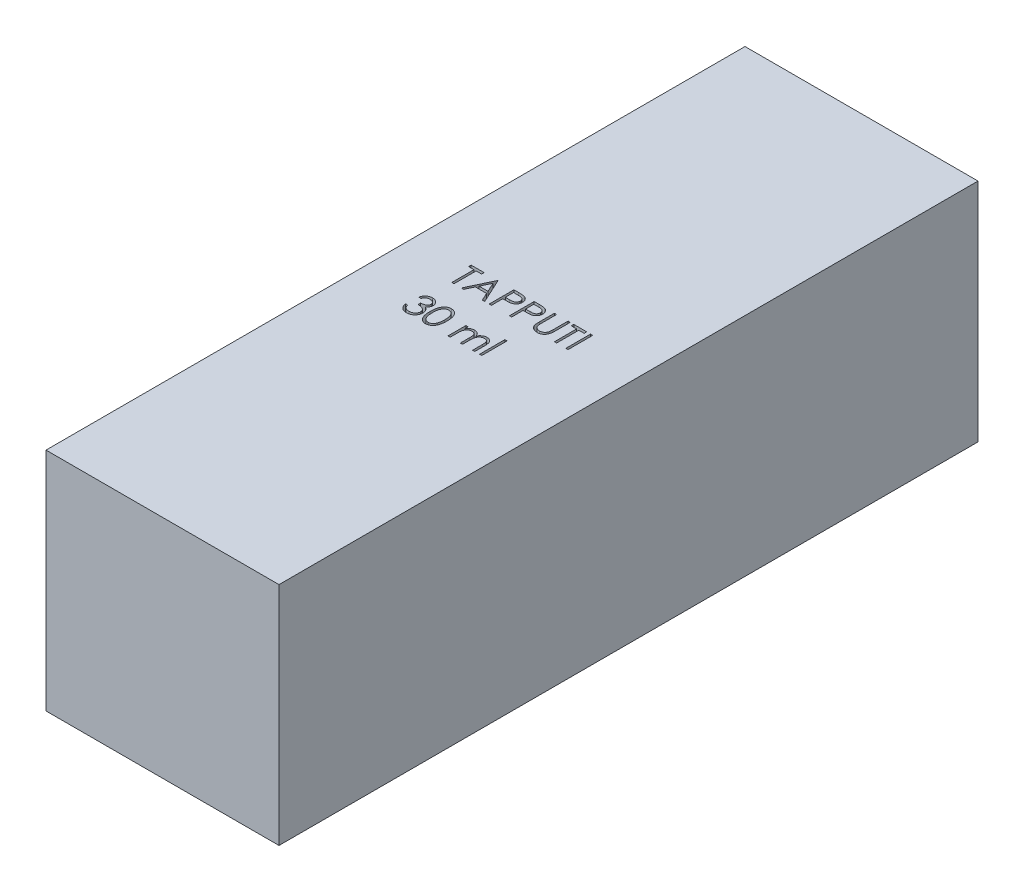
from build123d import *

# Parameters (mm, degrees)
SKETCH1_W           = 33
SKETCH1_H           = 99
BOSS_EXTRUDE1_DEPTH = 32
SKETCH2_W           = 0.314102564
SKETCH2_H           = 3.5
SKETCH2_H_2         = 3.58974359
CUT_EXTRUDE1_DEPTH  = 10


with BuildPart() as part:
    # Sketch1 → Boss-Extrude1 (new body)
    with BuildSketch(Plane(origin=(0, 0, 0), x_dir=(1, 0, 0), z_dir=(0, 1, 0))):
        Rectangle(SKETCH1_W, SKETCH1_H)
    extrude(amount=BOSS_EXTRUDE1_DEPTH)

    # Sketch2 → Cut-Extrude1 (cut)
    with BuildSketch(Plane(origin=(0, 32, 0), x_dir=(1, 0, 0), z_dir=(0, 1, 0))):
        Polygon((-9.084000918, 2.933551261), (-9.084000918, 3.29252562), (-7.244257328, 3.29252562), (-7.244257328, 2.933551261), (-8.007077841, 2.933551261), (-8.007077841, -0.20747438), (-8.321180405, -0.20747438), (-8.321180405, 2.933551261), align=None)
        Polygon((-5.269898353, 3.29252562), (-3.654513738, -0.20747438), (-3.995960052, -0.20747438), (-4.513387937, 0.914320492), (-6.100026559, 0.914320492), (-6.632178001, -0.20747438), (-6.975026559, -0.20747438), (-5.314770148, 3.29252562), align=None)
        Polygon((-5.29583986, 2.610334114), (-5.929653962, 1.273294851), (-4.67885268, 1.273294851), align=None, mode=Mode.SUBTRACT)
        with BuildLine():
            Line((-3.02630861, 3.29252562), (-2.339910373, 3.29252562))
            add(Edge.make_bspline(
                [(-2.339910373, 3.29252562), (-2.292699467, 3.292473724), (-2.202241274, 3.292374288), (-2.072526218, 3.289359543), (-1.954716486, 3.285332851), (-1.849066105, 3.279750957), (-1.755250007, 3.273154367), (-1.673692708, 3.263902328), (-1.603753151, 3.254242032), (-1.561846702, 3.244420626), (-1.542734892, 3.239941486)],
                knots=[0, 0, 0, 0, 0.000141628, 0.000271366, 0.00038923, 0.000495248, 0.00058876, 0.000671296, 0.000741499, 0.00080036, 0.00080036, 0.00080036, 0.00080036], degree=3))
            add(Edge.make_bspline(
                [(-1.542734892, 3.239941486), (-1.518541358, 3.233319536), (-1.470724381, 3.220231674), (-1.401823338, 3.194017951), (-1.336269492, 3.162935785), (-1.273837934, 3.127511846), (-1.215295851, 3.086226281), (-1.15976981, 3.040752664), (-1.10774983, 2.990041095), (-1.059528438, 2.934660355), (-1.01524364, 2.875540145), (-0.977113957, 2.811797915), (-0.94518673, 2.744506612), (-0.917803459, 2.673713041), (-0.898095004, 2.598822717), (-0.883248105, 2.520356005), (-0.873824477, 2.438321315), (-0.872921915, 2.382261447), (-0.872462456, 2.353723537)],
                knots=[0, 0, 0, 0, 7.5216e-05, 0.00014866, 0.000220794, 0.000292713, 0.000363707, 0.000435434, 0.000507823, 0.000581364, 0.000655543, 0.000729131, 0.000803767, 0.000878771, 0.000956497, 0.001035702, 0.001118238, 0.001203821, 0.001203821, 0.001203821, 0.001203821], degree=3))
            add(Edge.make_bspline(
                [(-0.872462456, 2.353723537), (-0.872883881, 2.32494576), (-0.873708427, 2.268640096), (-0.883604712, 2.186267308), (-0.896934904, 2.107548918), (-0.917431956, 2.032659467), (-0.944277629, 1.962043697), (-0.975769682, 1.894622465), (-1.013753212, 1.831542793), (-1.057398042, 1.772575675), (-1.105949636, 1.717665763), (-1.159202575, 1.667210969), (-1.216941867, 1.62150663), (-1.278984015, 1.580450286), (-1.345933864, 1.544994007), (-1.416776017, 1.513236702), (-1.492126234, 1.486565641), (-1.544268748, 1.47253558), (-1.570779764, 1.465402223)],
                knots=[0, 0, 0, 0, 8.6284e-05, 0.00016882, 0.000248587, 0.000325638, 0.000401297, 0.000474998, 0.000548586, 0.000621785, 0.0006948, 0.0007682, 0.000841564, 0.000915458, 0.000991056, 0.00106858, 0.00114819, 0.001230532, 0.001230532, 0.001230532, 0.001230532], degree=3))
            add(Edge.make_bspline(
                [(-1.570779764, 1.465402223), (-1.592707098, 1.460739242), (-1.640762125, 1.450520048), (-1.719904847, 1.439111591), (-1.812050233, 1.42937399), (-1.917072513, 1.422072852), (-2.034877418, 1.415822484), (-2.165528675, 1.41085439), (-2.309282752, 1.408124536), (-2.409553997, 1.407983743), (-2.461905565, 1.407910236)],
                knots=[0, 0, 0, 0, 6.7238e-05, 0.000147357, 0.000239727, 0.000345177, 0.000463135, 0.000593636, 0.000737393, 0.000894446, 0.000894446, 0.000894446, 0.000894446], degree=3))
            Line((-2.461905565, 1.407910236), (-2.712206046, 1.407910236))
            Line((-2.712206046, 1.407910236), (-2.712206046, -0.20747438))
            Line((-2.712206046, -0.20747438), (-3.02630861, -0.20747438))
            Line((-3.02630861, -0.20747438), (-3.02630861, 3.29252562))
        make_face()
        with BuildLine():
            Line((-2.712206046, 2.933551261), (-2.712206046, 1.766884595))
            Line((-2.712206046, 1.766884595), (-2.099425597, 1.759172255))
            add(Edge.make_bspline(
                [(-2.099425597, 1.759172255), (-2.069505671, 1.759156791), (-2.011745871, 1.759126939), (-1.928309648, 1.763112163), (-1.850900361, 1.767712695), (-1.779755785, 1.774448619), (-1.714843851, 1.783969876), (-1.656056322, 1.793581614), (-1.603849039, 1.807486977), (-1.542749837, 1.826210046), (-1.47466649, 1.858142661), (-1.400598941, 1.904492552), (-1.337828355, 1.96357326), (-1.283510058, 2.030001091), (-1.24040418, 2.10390022), (-1.208848188, 2.182969157), (-1.190307031, 2.266397007), (-1.187820837, 2.323485146), (-1.18656502, 2.352321293)],
                knots=[0, 0, 0, 0, 8.9746e-05, 0.000173253, 0.000250533, 0.00032239, 0.000387534, 0.00044736, 0.000500926, 0.000549486, 0.000638903, 0.000725641, 0.000810488, 0.000896226, 0.000982324, 0.00106604, 0.001150757, 0.001237226, 0.001237226, 0.001237226, 0.001237226], degree=3))
            add(Edge.make_bspline(
                [(-1.18656502, 2.352321293), (-1.187827667, 2.380459807), (-1.190337652, 2.436395689), (-1.208993515, 2.518374449), (-1.240342829, 2.596610154), (-1.283799423, 2.669583239), (-1.336540553, 2.735772043), (-1.397839896, 2.79326917), (-1.467553158, 2.839490873), (-1.532401389, 2.869324155), (-1.590002575, 2.88753943), (-1.640034534, 2.900284271), (-1.696525209, 2.910459877), (-1.759492988, 2.91869938), (-1.828449822, 2.925752841), (-1.903988137, 2.930538818), (-1.98582178, 2.933340274), (-2.042632351, 2.933479229), (-2.072081847, 2.933551261)],
                knots=[0, 0, 0, 0, 8.4371e-05, 0.000167719, 0.000250783, 0.000336277, 0.000421575, 0.000503926, 0.000587348, 0.000671427, 0.000717102, 0.000768457, 0.000826213, 0.000889178, 0.000958942, 0.001034123, 0.001116202, 0.001204546, 0.001204546, 0.001204546, 0.001204546], degree=3))
            Line((-2.072081847, 2.933551261), (-2.712206046, 2.933551261))
        make_face(mode=Mode.SUBTRACT)
        with BuildLine():
            Line((-0.154513738, 3.29252562), (0.531884499, 3.29252562))
            add(Edge.make_bspline(
                [(0.531884499, 3.29252562), (0.579095405, 3.292473724), (0.669553598, 3.292374288), (0.799268654, 3.289359543), (0.917078385, 3.285332851), (1.022728766, 3.279750957), (1.116544864, 3.273154367), (1.198102164, 3.263902328), (1.26804172, 3.254242032), (1.30994817, 3.244420626), (1.32905998, 3.239941486)],
                knots=[0, 0, 0, 0, 0.000141628, 0.000271366, 0.00038923, 0.000495248, 0.00058876, 0.000671296, 0.000741499, 0.00080036, 0.00080036, 0.00080036, 0.00080036], degree=3))
            add(Edge.make_bspline(
                [(1.32905998, 3.239941486), (1.353253514, 3.233319536), (1.401070491, 3.220231674), (1.469971534, 3.194017951), (1.535525379, 3.162935785), (1.597956938, 3.127511846), (1.656499021, 3.086226281), (1.712025062, 3.040752664), (1.764045042, 2.990041095), (1.812266434, 2.934660355), (1.856551232, 2.875540145), (1.894680914, 2.811797915), (1.926608141, 2.744506612), (1.953991413, 2.673713041), (1.973699867, 2.598822717), (1.988546767, 2.520356005), (1.997970395, 2.438321315), (1.998872957, 2.382261447), (1.999332416, 2.353723537)],
                knots=[0, 0, 0, 0, 7.5216e-05, 0.00014866, 0.000220794, 0.000292713, 0.000363707, 0.000435434, 0.000507823, 0.000581364, 0.000655543, 0.000729131, 0.000803767, 0.000878771, 0.000956497, 0.001035702, 0.001118238, 0.001203821, 0.001203821, 0.001203821, 0.001203821], degree=3))
            add(Edge.make_bspline(
                [(1.999332416, 2.353723537), (1.998910991, 2.32494576), (1.998086445, 2.268640096), (1.98819016, 2.186267308), (1.974859968, 2.107548918), (1.954362916, 2.032659467), (1.927517243, 1.962043697), (1.89602519, 1.894622465), (1.85804166, 1.831542793), (1.81439683, 1.772575675), (1.765845235, 1.717665763), (1.712592297, 1.667210969), (1.654853005, 1.62150663), (1.592810857, 1.580450286), (1.525861008, 1.544994007), (1.455018854, 1.513236702), (1.379668638, 1.486565641), (1.327526124, 1.47253558), (1.301015108, 1.465402223)],
                knots=[0, 0, 0, 0, 8.6284e-05, 0.00016882, 0.000248587, 0.000325638, 0.000401297, 0.000474998, 0.000548586, 0.000621785, 0.0006948, 0.0007682, 0.000841564, 0.000915458, 0.000991056, 0.00106858, 0.00114819, 0.001230532, 0.001230532, 0.001230532, 0.001230532], degree=3))
            add(Edge.make_bspline(
                [(1.301015108, 1.465402223), (1.279087774, 1.460739242), (1.231032747, 1.450520048), (1.151890025, 1.439111591), (1.059744639, 1.42937399), (0.954722359, 1.422072852), (0.836917454, 1.415822484), (0.706266196, 1.41085439), (0.562512119, 1.408124536), (0.462240875, 1.407983743), (0.409889307, 1.407910236)],
                knots=[0, 0, 0, 0, 6.7238e-05, 0.000147357, 0.000239727, 0.000345177, 0.000463135, 0.000593636, 0.000737393, 0.000894446, 0.000894446, 0.000894446, 0.000894446], degree=3))
            Line((0.409889307, 1.407910236), (0.159588826, 1.407910236))
            Line((0.159588826, 1.407910236), (0.159588826, -0.20747438))
            Line((0.159588826, -0.20747438), (-0.154513738, -0.20747438))
            Line((-0.154513738, -0.20747438), (-0.154513738, 3.29252562))
        make_face()
        with BuildLine():
            Line((0.159588826, 2.933551261), (0.159588826, 1.766884595))
            Line((0.159588826, 1.766884595), (0.772369275, 1.759172255))
            add(Edge.make_bspline(
                [(0.772369275, 1.759172255), (0.802289201, 1.759156791), (0.860049001, 1.759126939), (0.943485224, 1.763112163), (1.020894511, 1.767712695), (1.092039086, 1.774448619), (1.156951021, 1.783969876), (1.21573855, 1.793581614), (1.267945833, 1.807486977), (1.329045034, 1.826210046), (1.397128382, 1.858142661), (1.47119593, 1.904492552), (1.533966517, 1.96357326), (1.588284814, 2.030001091), (1.631390691, 2.10390022), (1.662946684, 2.182969157), (1.681487841, 2.266397007), (1.683974035, 2.323485146), (1.685229852, 2.352321293)],
                knots=[0, 0, 0, 0, 8.9746e-05, 0.000173253, 0.000250533, 0.00032239, 0.000387534, 0.00044736, 0.000500926, 0.000549486, 0.000638903, 0.000725641, 0.000810488, 0.000896226, 0.000982324, 0.00106604, 0.001150757, 0.001237226, 0.001237226, 0.001237226, 0.001237226], degree=3))
            add(Edge.make_bspline(
                [(1.685229852, 2.352321293), (1.683967205, 2.380459807), (1.68145722, 2.436395689), (1.662801357, 2.518374449), (1.631452043, 2.596610154), (1.587995449, 2.669583239), (1.535254319, 2.735772043), (1.473954976, 2.79326917), (1.404241714, 2.839490873), (1.339393483, 2.869324155), (1.281792297, 2.88753943), (1.231760337, 2.900284271), (1.175269663, 2.910459877), (1.112301883, 2.91869938), (1.043345049, 2.925752841), (0.967806735, 2.930538818), (0.885973091, 2.933340274), (0.82916252, 2.933479229), (0.799713025, 2.933551261)],
                knots=[0, 0, 0, 0, 8.4371e-05, 0.000167719, 0.000250783, 0.000336277, 0.000421575, 0.000503926, 0.000587348, 0.000671427, 0.000717102, 0.000768457, 0.000826213, 0.000889178, 0.000958942, 0.001034123, 0.001116202, 0.001204546, 0.001204546, 0.001204546, 0.001204546], degree=3))
            Line((0.799713025, 2.933551261), (0.159588826, 2.933551261))
        make_face(mode=Mode.SUBTRACT)
        with BuildLine():
            Line((2.717281134, 3.29252562), (3.031383698, 3.29252562))
            Line((3.031383698, 3.29252562), (3.031383698, 1.195470332))
            add(Edge.make_bspline(
                [(3.031383698, 1.195470332), (3.031336954, 1.165789596), (3.031248249, 1.109465285), (3.031840763, 1.029296984), (3.033500131, 0.958024525), (3.034546291, 0.895373178), (3.036873625, 0.84163043), (3.038771671, 0.79650512), (3.041212228, 0.760210917), (3.044145346, 0.739029991), (3.045406134, 0.72992546)],
                knots=[0, 0, 0, 0, 8.9042e-05, 0.000168973, 0.000240502, 0.000302917, 0.000356945, 0.000401866, 0.000438432, 0.000465999, 0.000465999, 0.000465999, 0.000465999], degree=3))
            add(Edge.make_bspline(
                [(3.045406134, 0.72992546), (3.050583593, 0.697078697), (3.060646779, 0.633235967), (3.086293157, 0.542327686), (3.122110658, 0.460396227), (3.1645537, 0.384884936), (3.220486312, 0.317895576), (3.287489847, 0.256183923), (3.368667616, 0.202212119), (3.458928221, 0.152861307), (3.556213459, 0.113196225), (3.655624725, 0.08320286), (3.755667704, 0.06492396), (3.822643869, 0.062807421), (3.855902929, 0.061756389)],
                knots=[0, 0, 0, 0, 9.971e-05, 0.000193801, 0.000282365, 0.000367504, 0.000452699, 0.000543015, 0.000639862, 0.000744331, 0.000851226, 0.000954377, 0.001055468, 0.001155185, 0.001155185, 0.001155185, 0.001155185], degree=3))
            add(Edge.make_bspline(
                [(3.855902929, 0.061756389), (3.884456669, 0.06283024), (3.941399231, 0.064971738), (4.026005662, 0.078233169), (4.10840577, 0.102133735), (4.18900645, 0.132973493), (4.264557435, 0.173721084), (4.335100877, 0.220791924), (4.398064811, 0.2760028), (4.455522809, 0.337103144), (4.505557744, 0.406042944), (4.548928886, 0.481321082), (4.584454816, 0.564070429), (4.601998341, 0.622224851), (4.611011102, 0.652100941)],
                knots=[0, 0, 0, 0, 8.5678e-05, 0.00017086, 0.000256092, 0.000342674, 0.000429242, 0.000513055, 0.000596556, 0.000679898, 0.000764179, 0.00085149, 0.000940054, 0.001033621, 0.001033621, 0.001033621, 0.001033621], degree=3))
            add(Edge.make_bspline(
                [(4.611011102, 0.652100941), (4.614011227, 0.664449515), (4.620696715, 0.691967115), (4.62694376, 0.738488406), (4.633450286, 0.79337777), (4.637964856, 0.857029582), (4.642366076, 0.929230555), (4.644999149, 1.010356813), (4.646216182, 1.100113773), (4.646578862, 1.162750935), (4.646768313, 1.195470332)],
                knots=[0, 0, 0, 0, 3.81e-05, 8.4902e-05, 0.000140649, 0.000203941, 0.000276279, 0.000357657, 0.000447412, 0.000545571, 0.000545571, 0.000545571, 0.000545571], degree=3))
            Line((4.646768313, 1.195470332), (4.646768313, 3.29252562))
            Line((4.646768313, 3.29252562), (4.960870877, 3.29252562))
            Line((4.960870877, 3.29252562), (4.960870877, 1.178643409))
            add(Edge.make_bspline(
                [(4.960870877, 1.178643409), (4.960616757, 1.14054503), (4.960120826, 1.066193727), (4.955820249, 0.957242368), (4.948963249, 0.853889386), (4.939275161, 0.75612089), (4.926438158, 0.664286731), (4.912162938, 0.577581963), (4.893983405, 0.49662897), (4.872750003, 0.420796552), (4.848476455, 0.348611039), (4.817035307, 0.280102424), (4.781610807, 0.213188025), (4.739596154, 0.148879916), (4.692384771, 0.086893362), (4.638933091, 0.027604287), (4.58100893, -0.029934759), (4.51764937, -0.084247825), (4.449898845, -0.134056502), (4.377958887, -0.177854273), (4.302382118, -0.21487789), (4.223364991, -0.245353815), (4.140873789, -0.268268414), (4.054906429, -0.28534357), (3.965267236, -0.295045867), (3.904302579, -0.296487797), (3.873430973, -0.29721797)],
                knots=[0, 0, 0, 0, 0.000114291, 0.000223047, 0.000327049, 0.000424998, 0.000517708, 0.000605194, 0.000688542, 0.000766455, 0.0008414, 0.000916717, 0.000992315, 0.001068354, 0.001146882, 0.001225836, 0.001307639, 0.001391671, 0.001475952, 0.001559641, 0.001643989, 0.001728103, 0.001813335, 0.001900511, 0.00199079, 0.002083404, 0.002083404, 0.002083404, 0.002083404], degree=3))
            add(Edge.make_bspline(
                [(3.873430973, -0.29721797), (3.839761871, -0.296433204), (3.773703212, -0.294893498), (3.676365145, -0.286070748), (3.583050948, -0.269452353), (3.492775071, -0.248292409), (3.406766574, -0.219108672), (3.32387313, -0.185010547), (3.245514449, -0.143133287), (3.17041932, -0.096539894), (3.100594564, -0.044115256), (3.036497161, 0.013024918), (2.97802129, 0.073965295), (2.926152594, 0.139365661), (2.880031709, 0.208717368), (2.840301496, 0.282216608), (2.806188252, 0.359834924), (2.788581685, 0.413788125), (2.779680973, 0.44106328)],
                knots=[0, 0, 0, 0, 0.000101022, 0.000198206, 0.000292839, 0.000385177, 0.00047608, 0.000565014, 0.000653769, 0.000742283, 0.000829923, 0.000915339, 0.000999643, 0.001082971, 0.00116542, 0.001249186, 0.001333332, 0.001419362, 0.001419362, 0.001419362, 0.001419362], degree=3))
            add(Edge.make_bspline(
                [(2.779680973, 0.44106328), (2.774503815, 0.459695855), (2.763274444, 0.500110324), (2.751249146, 0.566996812), (2.741140065, 0.64401173), (2.731634506, 0.731160348), (2.726025548, 0.828510215), (2.72110811, 0.936019131), (2.717246491, 1.053817093), (2.717269263, 1.135871608), (2.717281134, 1.178643409)],
                knots=[0, 0, 0, 0, 5.799e-05, 0.000125782, 0.000203619, 0.000291034, 0.000388694, 0.000496078, 0.000613919, 0.000742226, 0.000742226, 0.000742226, 0.000742226], degree=3))
            Line((2.717281134, 1.178643409), (2.717281134, 3.29252562))
        make_face()
        Polygon((5.454460621, 2.933551261), (5.454460621, 3.29252562), (7.294204211, 3.29252562), (7.294204211, 2.933551261), (6.531383698, 2.933551261), (6.531383698, -0.20747438), (6.217281134, -0.20747438), (6.217281134, 2.933551261), align=None)
        with Locations((7.989717031, 1.54252562)):
            Rectangle(SKETCH2_W, SKETCH2_H)
        with BuildLine():
            Line((-8.545539379, -4.348500021), (-8.859641943, -4.348500021))
            add(Edge.make_bspline(
                [(-8.859641943, -4.348500021), (-8.851132392, -4.313267537), (-8.834496917, -4.244390912), (-8.799799343, -4.145983652), (-8.762000088, -4.05286013), (-8.716610984, -3.966764057), (-8.667102229, -3.885965154), (-8.610379508, -3.812296029), (-8.549059785, -3.743883064), (-8.481234836, -3.683169826), (-8.410106174, -3.628192097), (-8.334671555, -3.58131704), (-8.256448661, -3.540992887), (-8.174895528, -3.507772655), (-8.089769356, -3.482747131), (-8.001839733, -3.464590326), (-7.910876233, -3.452799212), (-7.849128642, -3.451648448), (-7.817774956, -3.451064123)],
                knots=[0, 0, 0, 0, 0.000108665, 0.000212431, 0.000312691, 0.000409905, 0.000504067, 0.000596618, 0.000688443, 0.000779278, 0.000869306, 0.00095782, 0.001045306, 0.001133058, 0.001221569, 0.001311085, 0.001402223, 0.001496238, 0.001496238, 0.001496238, 0.001496238], degree=3))
            add(Edge.make_bspline(
                [(-7.817774956, -3.451064123), (-7.772092214, -3.452443354), (-7.681723203, -3.455171729), (-7.548960156, -3.480086166), (-7.420933337, -3.519511298), (-7.299044089, -3.573985025), (-7.185825657, -3.641172338), (-7.08508947, -3.721137075), (-6.998200959, -3.812336377), (-6.925306581, -3.913068941), (-6.868231582, -4.02072445), (-6.826145209, -4.131524608), (-6.800523528, -4.245206579), (-6.797202971, -4.321963858), (-6.795539379, -4.360419091)],
                knots=[0, 0, 0, 0, 0.000136936, 0.000270885, 0.000403723, 0.000538055, 0.000670441, 0.000797677, 0.000922646, 0.001047185, 0.00116951, 0.001287103, 0.001401935, 0.001517226, 0.001517226, 0.001517226, 0.001517226], degree=3))
            add(Edge.make_bspline(
                [(-6.795539379, -4.360419091), (-6.79670297, -4.397425886), (-6.798979937, -4.469842441), (-6.818313643, -4.575563938), (-6.850849906, -4.675205538), (-6.895919668, -4.7691867), (-6.954261218, -4.85691154), (-7.024933915, -4.938577431), (-7.108436577, -5.014546589), (-7.171715515, -5.058066062), (-7.204293385, -5.080471175)],
                knots=[0, 0, 0, 0, 0.000110957, 0.000217125, 0.000321111, 0.000424595, 0.000528824, 0.000636204, 0.000747885, 0.000866393, 0.000866393, 0.000866393, 0.000866393], degree=3))
            add(Edge.make_bspline(
                [(-7.204293385, -5.080471175), (-7.167061631, -5.098449346), (-7.093294757, -5.134069304), (-6.992744227, -5.203925061), (-6.901466352, -5.284581409), (-6.850562633, -5.347524062), (-6.824986494, -5.379149059)],
                knots=[0, 0, 0, 0, 0.000123863, 0.000245408, 0.000366052, 0.000487879, 0.000487879, 0.000487879, 0.000487879], degree=3))
            add(Edge.make_bspline(
                [(-6.824986494, -5.379149059), (-6.808145152, -5.402206811), (-6.774738256, -5.447944727), (-6.733502722, -5.521481153), (-6.696093608, -5.595832643), (-6.666943389, -5.672992049), (-6.644369522, -5.752065062), (-6.62823349, -5.833187458), (-6.618209349, -5.916425481), (-6.616773797, -5.972737961), (-6.6160522, -6.001044091)],
                knots=[0, 0, 0, 0, 8.5583e-05, 0.000169764, 0.000252544, 0.000335098, 0.000416766, 0.000498992, 0.000583001, 0.000667909, 0.000667909, 0.000667909, 0.000667909], degree=3))
            add(Edge.make_bspline(
                [(-6.6160522, -6.001044091), (-6.617846713, -6.050053813), (-6.621427295, -6.147842614), (-6.653431369, -6.292317336), (-6.70304461, -6.433542838), (-6.773501546, -6.568617678), (-6.859369055, -6.694998059), (-6.961526379, -6.808074368), (-7.078812788, -6.905272972), (-7.209618436, -6.9864832), (-7.351335565, -7.051401122), (-7.502911157, -7.096458565), (-7.662161211, -7.125804565), (-7.771368508, -7.128951434), (-7.826889539, -7.130551303)],
                knots=[0, 0, 0, 0, 0.000146863, 0.000293035, 0.000441833, 0.000594857, 0.000748684, 0.000899086, 0.001050437, 0.001204129, 0.001359752, 0.001516561, 0.001677477, 0.001843893, 0.001843893, 0.001843893, 0.001843893], degree=3))
            add(Edge.make_bspline(
                [(-7.826889539, -7.130551303), (-7.86430884, -7.12968309), (-7.937937545, -7.127974735), (-8.046181043, -7.116296134), (-8.149502742, -7.094966129), (-8.24804234, -7.066262824), (-8.341887377, -7.029871082), (-8.430751482, -6.984552384), (-8.515181375, -6.931240882), (-8.594380327, -6.869307294), (-8.668338894, -6.800025954), (-8.735091618, -6.722166944), (-8.795751411, -6.63716954), (-8.84869405, -6.544046484), (-8.896331003, -6.444001227), (-8.935511959, -6.335752728), (-8.969997528, -6.220268706), (-8.986030992, -6.139790966), (-8.994257328, -6.098500021)],
                knots=[0, 0, 0, 0, 0.000112258, 0.000220887, 0.000326076, 0.000428356, 0.000528479, 0.000627563, 0.000727152, 0.000827569, 0.00092875, 0.001030654, 0.001134734, 0.001241526, 0.001351611, 0.001466743, 0.00158655, 0.001712791, 0.001712791, 0.001712791, 0.001712791], degree=3))
            Line((-8.994257328, -6.098500021), (-8.680154764, -6.098500021))
            add(Edge.make_bspline(
                [(-8.680154764, -6.098500021), (-8.671971472, -6.125449034), (-8.65605426, -6.177867206), (-8.628959962, -6.253307511), (-8.598091689, -6.322465565), (-8.564977131, -6.385848687), (-8.530198685, -6.444081089), (-8.49128376, -6.495622958), (-8.451114615, -6.54273816), (-8.420835261, -6.569282772), (-8.406016142, -6.582274059)],
                knots=[0, 0, 0, 0, 8.4487e-05, 0.000164335, 0.000240293, 0.00031148, 0.000378817, 0.000443461, 0.000505064, 0.000564113, 0.000564113, 0.000564113, 0.000564113], degree=3))
            add(Edge.make_bspline(
                [(-8.406016142, -6.582274059), (-8.386419565, -6.597382393), (-8.347286902, -6.627552425), (-8.283518671, -6.666054054), (-8.216453785, -6.699415079), (-8.144639111, -6.724898775), (-8.069624341, -6.746476435), (-7.990196975, -6.760596954), (-7.907057758, -6.770285126), (-7.850289995, -6.771140057), (-7.821280565, -6.771576944)],
                knots=[0, 0, 0, 0, 7.418e-05, 0.000148131, 0.000223072, 0.000298488, 0.0003764, 0.000456984, 0.000540217, 0.000627201, 0.000627201, 0.000627201, 0.000627201], degree=3))
            add(Edge.make_bspline(
                [(-7.821280565, -6.771576944), (-7.788527062, -6.770961039), (-7.724480415, -6.769756689), (-7.631025556, -6.758680982), (-7.542118109, -6.742550569), (-7.458745183, -6.717637586), (-7.379814675, -6.686856735), (-7.306433026, -6.648208329), (-7.23763692, -6.602863608), (-7.174307514, -6.551324449), (-7.117362007, -6.494902954), (-7.067222493, -6.435889883), (-7.024597832, -6.374534053), (-6.990214254, -6.310495932), (-6.963063703, -6.244040703), (-6.944580503, -6.174981874), (-6.931728988, -6.103884608), (-6.930682376, -6.055555639), (-6.930154764, -6.031192329)],
                knots=[0, 0, 0, 0, 9.822e-05, 0.00019206, 0.00028199, 0.000368957, 0.000452673, 0.000535779, 0.000617257, 0.000699492, 0.000780303, 0.000857417, 0.000931514, 0.001003978, 0.001075065, 0.001146335, 0.001218144, 0.001291145, 0.001291145, 0.001291145, 0.001291145], degree=3))
            add(Edge.make_bspline(
                [(-6.930154764, -6.031192329), (-6.931685065, -5.99858099), (-6.934738054, -5.933520581), (-6.958046633, -5.837803007), (-6.996385497, -5.745579595), (-7.050058009, -5.658423805), (-7.115393737, -5.577647903), (-7.191758644, -5.505576421), (-7.279786873, -5.44610633), (-7.360806742, -5.405017673), (-7.432571898, -5.376980598), (-7.493987283, -5.358305634), (-7.562743886, -5.342491978), (-7.638010235, -5.327779706), (-7.720353451, -5.315258358), (-7.809683889, -5.304816542), (-7.906019651, -5.296461501), (-7.972710817, -5.292730406), (-8.007077841, -5.290807713)],
                knots=[0, 0, 0, 0, 9.7761e-05, 0.000195035, 0.000293731, 0.000396299, 0.00050098, 0.000604654, 0.000710058, 0.000818548, 0.000876487, 0.000941025, 0.001010919, 0.001088059, 0.001171055, 0.001260716, 0.001357836, 0.001461094, 0.001461094, 0.001461094, 0.001461094], degree=3))
            Line((-8.007077841, -5.290807713), (-8.007077841, -4.931833354))
            add(Edge.make_bspline(
                [(-8.007077841, -4.931833354), (-7.963776675, -4.93109855), (-7.878960328, -4.92965925), (-7.755066024, -4.91225124), (-7.636592711, -4.888170612), (-7.526165969, -4.85128542), (-7.425517256, -4.808445123), (-7.338197654, -4.758592913), (-7.265430507, -4.703178164), (-7.207569435, -4.641345555), (-7.164040207, -4.575030507), (-7.132213409, -4.50591385), (-7.113413083, -4.433389789), (-7.110903416, -4.383895121), (-7.109641943, -4.359016848)],
                knots=[0, 0, 0, 0, 0.0001298, 0.000254247, 0.000374709, 0.000491998, 0.000602842, 0.000702416, 0.000792872, 0.000876214, 0.000955164, 0.001029842, 0.001103644, 0.00117823, 0.00117823, 0.00117823, 0.00117823], degree=3))
            add(Edge.make_bspline(
                [(-7.109641943, -4.359016848), (-7.110056354, -4.340739103), (-7.110880805, -4.304376396), (-7.121278083, -4.251251327), (-7.136902124, -4.199750381), (-7.158381853, -4.150092571), (-7.187132052, -4.102622297), (-7.221538038, -4.056934848), (-7.262506139, -4.013291069), (-7.309451586, -3.972610749), (-7.359863391, -3.933841512), (-7.415113166, -3.900927875), (-7.47353504, -3.872782813), (-7.535193695, -3.849573311), (-7.600289226, -3.832114023), (-7.668515783, -3.819578181), (-7.740003467, -3.811740527), (-7.788775199, -3.810612111), (-7.813568225, -3.810038482)],
                knots=[0, 0, 0, 0, 5.4759e-05, 0.000108941, 0.000161726, 0.000216044, 0.000270754, 0.000327825, 0.00038735, 0.000449943, 0.000514025, 0.000577874, 0.000642472, 0.000708366, 0.000775209, 0.000844379, 0.000916308, 0.00099068, 0.00099068, 0.00099068, 0.00099068], degree=3))
            add(Edge.make_bspline(
                [(-7.813568225, -3.810038482), (-7.853419893, -3.811429844), (-7.93125947, -3.814147498), (-8.043474387, -3.837950511), (-8.147793721, -3.875928595), (-8.227532387, -3.921261614), (-8.286414961, -3.966012048), (-8.328491899, -4.005094435), (-8.36981241, -4.048527258), (-8.407658087, -4.098985634), (-8.445932063, -4.153052424), (-8.480776625, -4.213476105), (-8.514636317, -4.2786805), (-8.535038867, -4.324776134), (-8.545539379, -4.348500021)],
                knots=[0, 0, 0, 0, 0.00011944, 0.000233294, 0.000342435, 0.0004514, 0.000506931, 0.000563998, 0.000623523, 0.000686492, 0.000753006, 0.000822147, 0.000895524, 0.000973336, 0.000973336, 0.000973336, 0.000973336], degree=3))
        make_face()
        with BuildLine():
            add(Edge.make_bspline(
                [(-6.301949635, -5.292209957), (-6.301621617, -5.236112569), (-6.300984437, -5.127142585), (-6.293896016, -4.968357943), (-6.282120674, -4.819397654), (-6.265983301, -4.680254588), (-6.246345321, -4.550892823), (-6.220129834, -4.431658066), (-6.190317032, -4.321998459), (-6.155764586, -4.221556411), (-6.116776797, -4.128978708), (-6.074342536, -4.042553507), (-6.026777742, -3.962411574), (-5.976800829, -3.887273784), (-5.922388757, -3.818370089), (-5.865089967, -3.754727427), (-5.802668091, -3.697816676), (-5.737245082, -3.645970374), (-5.668228618, -3.600520902), (-5.597585952, -3.560488163), (-5.524830846, -3.526288296), (-5.449764663, -3.49939786), (-5.373062105, -3.477187014), (-5.294455038, -3.461998066), (-5.213813674, -3.452441157), (-5.15938224, -3.45152749), (-5.13177736, -3.451064123)],
                knots=[0, 0, 0, 0, 0.000168282, 0.000326891, 0.000476705, 0.00061646, 0.000747059, 0.00086904, 0.000982494, 0.001087814, 0.001187428, 0.001283689, 0.001376399, 0.001466822, 0.001554203, 0.001639568, 0.001723424, 0.001807301, 0.001889751, 0.001971063, 0.002050735, 0.002130583, 0.002210036, 0.002290062, 0.002370508, 0.002453288, 0.002453288, 0.002453288, 0.002453288], degree=3))
            add(Edge.make_bspline(
                [(-5.13177736, -3.451064123), (-5.103941881, -3.451551939), (-5.048585872, -3.452522049), (-4.966745497, -3.461845992), (-4.886795816, -3.477317115), (-4.809077677, -3.49923809), (-4.73295269, -3.526433766), (-4.659016283, -3.560520883), (-4.586809201, -3.600199751), (-4.517478914, -3.646823628), (-4.450264298, -3.698805904), (-4.386816335, -3.757568573), (-4.327129249, -3.822518292), (-4.270453944, -3.892960156), (-4.218398347, -3.970245241), (-4.168824914, -4.053029351), (-4.124452879, -4.142760216), (-4.081718203, -4.237940684), (-4.044831217, -4.341204342), (-4.011564971, -4.451969103), (-3.984686003, -4.57154329), (-3.96229673, -4.699299535), (-3.944951835, -4.835707018), (-3.932319192, -4.980473334), (-3.925646107, -5.133693724), (-3.924389406, -5.238451574), (-3.923744507, -5.292209957)],
                knots=[0, 0, 0, 0, 8.3481e-05, 0.000166017, 0.000246731, 0.000327534, 0.000408041, 0.000488986, 0.000571522, 0.000654944, 0.000739373, 0.000826202, 0.000914021, 0.001003809, 0.001097153, 0.001193347, 0.001293057, 0.001397277, 0.001506176, 0.001621751, 0.001744038, 0.001873599, 0.002010742, 0.002156422, 0.002309427, 0.002470709, 0.002470709, 0.002470709, 0.002470709], degree=3))
            add(Edge.make_bspline(
                [(-3.923744507, -5.292209957), (-3.924396092, -5.345733865), (-3.925665678, -5.450023017), (-3.932244385, -5.602553992), (-3.945203016, -5.746552035), (-3.961413004, -5.882362498), (-3.983863967, -6.009420116), (-4.011469133, -6.128164565), (-4.042119456, -6.239108637), (-4.07995425, -6.341343448), (-4.12136496, -6.436295171), (-4.166420157, -6.524962319), (-4.214689983, -6.608128612), (-4.267278728, -6.685128359), (-4.323332141, -6.756507016), (-4.38404993, -6.821004639), (-4.447720515, -6.880175311), (-4.515132931, -6.932826938), (-4.585544482, -6.978911743), (-4.657503559, -7.020125593), (-4.732286942, -7.053358288), (-4.808199895, -7.081893329), (-4.886328261, -7.103693781), (-4.966574652, -7.118767637), (-5.048530888, -7.129339485), (-5.103932453, -7.130145965), (-5.13177736, -7.130551303)],
                knots=[0, 0, 0, 0, 0.000160581, 0.000312886, 0.000457868, 0.000594226, 0.000723097, 0.000844701, 0.000959884, 0.001068125, 0.001171421, 0.001270505, 0.001366343, 0.001459687, 0.001550023, 0.00163832, 0.001725149, 0.001810562, 0.001894568, 0.001977446, 0.00205903, 0.002139777, 0.00222058, 0.002301983, 0.002384599, 0.00246808, 0.00246808, 0.00246808, 0.00246808], degree=3))
            add(Edge.make_bspline(
                [(-5.13177736, -7.130551303), (-5.159381474, -7.130084947), (-5.213811399, -7.129165386), (-5.294463824, -7.119651654), (-5.372746267, -7.104356151), (-5.449045022, -7.082939547), (-5.523751537, -7.05672471), (-5.595847823, -7.022571027), (-5.666135507, -6.983236958), (-5.734427063, -6.938441536), (-5.799439224, -6.887119853), (-5.861537829, -6.830355565), (-5.919162848, -6.766732153), (-5.972796944, -6.69725423), (-6.023771032, -6.622560988), (-6.070660406, -6.541632615), (-6.11403126, -6.454790004), (-6.15367475, -6.361472094), (-6.188823414, -6.260317166), (-6.219871122, -6.150167987), (-6.244385279, -6.030052351), (-6.265368235, -5.900934984), (-6.282292618, -5.762261054), (-6.293846943, -5.613955275), (-6.300988258, -5.456110067), (-6.301623329, -5.347840292), (-6.301949635, -5.292209957)],
                knots=[0, 0, 0, 0, 8.278e-05, 0.000163226, 0.000243252, 0.00032184, 0.00040079, 0.000480463, 0.00056082, 0.000642298, 0.000725191, 0.000809047, 0.000894412, 0.000982346, 0.001072188, 0.001165503, 0.001262704, 0.001363236, 0.001469448, 0.001583766, 0.001706286, 0.001836995, 0.001976138, 0.002125253, 0.002283161, 0.002450041, 0.002450041, 0.002450041, 0.002450041], degree=3))
        make_face()
        with BuildLine():
            add(Edge.make_bspline(
                [(-5.987847071, -5.290807713), (-5.987727624, -5.337556412), (-5.987495801, -5.428286457), (-5.9814396, -5.560129718), (-5.973189368, -5.683100047), (-5.962548071, -5.797353583), (-5.946745123, -5.902503596), (-5.929038335, -5.999273279), (-5.907490245, -6.087150516), (-5.881995227, -6.166738326), (-5.852956131, -6.239387395), (-5.821250267, -6.30698861), (-5.787189544, -6.370340546), (-5.749070393, -6.428874155), (-5.70755533, -6.482780319), (-5.663582071, -6.533013151), (-5.615509487, -6.577810133), (-5.549005744, -6.631536988), (-5.46120927, -6.687056121), (-5.350588815, -6.735402211), (-5.236920364, -6.765784668), (-5.159769114, -6.769648424), (-5.121260533, -6.771576944)],
                knots=[0, 0, 0, 0, 0.000140231, 0.000272162, 0.000395845, 0.00050998, 0.000616273, 0.00071473, 0.000805025, 0.000887508, 0.000965234, 0.00103957, 0.001111417, 0.001180842, 0.001248855, 0.001315406, 0.001380877, 0.0014457, 0.001571746, 0.00169106, 0.001806864, 0.001922266, 0.001922266, 0.001922266, 0.001922266], degree=3))
            add(Edge.make_bspline(
                [(-5.121260533, -6.771576944), (-5.082502861, -6.769979163), (-5.005067538, -6.7667869), (-4.891933743, -6.735988163), (-4.782103473, -6.689518623), (-4.696031533, -6.634571118), (-4.630548989, -6.582242789), (-4.583631999, -6.53762814), (-4.540569951, -6.487672273), (-4.499727876, -6.433772977), (-4.4622688, -6.374900493), (-4.428205662, -6.311337918), (-4.397122315, -6.24290874), (-4.379413269, -6.195139001), (-4.370359091, -6.170715566)],
                knots=[0, 0, 0, 0, 0.000116044, 0.000231848, 0.000349318, 0.000472837, 0.000536674, 0.000600645, 0.000666733, 0.000734322, 0.000803367, 0.000875831, 0.000950509, 0.001028633, 0.001028633, 0.001028633, 0.001028633], degree=3))
            add(Edge.make_bspline(
                [(-4.370359091, -6.170715566), (-4.359807323, -6.139485826), (-4.338382709, -6.076076062), (-4.310770935, -5.97771241), (-4.289025536, -5.874509646), (-4.26946217, -5.767084529), (-4.256109114, -5.654644828), (-4.245361301, -5.537538444), (-4.239030614, -5.415677082), (-4.238245863, -5.332882091), (-4.237847071, -5.290807713)],
                knots=[0, 0, 0, 0, 9.8886e-05, 0.00020078, 0.000306259, 0.000415188, 0.00052824, 0.000645799, 0.000767957, 0.000894177, 0.000894177, 0.000894177, 0.000894177], degree=3))
            add(Edge.make_bspline(
                [(-4.237847071, -5.290807713), (-4.238397261, -5.248740141), (-4.239473548, -5.166446976), (-4.243587536, -5.045928795), (-4.254211111, -4.931461034), (-4.266010229, -4.822550562), (-4.283407451, -4.719800259), (-4.302165257, -4.622349954), (-4.32736647, -4.531406929), (-4.354286245, -4.445547347), (-4.38509664, -4.365746693), (-4.419012374, -4.291632906), (-4.455234133, -4.222848182), (-4.494576374, -4.15958124), (-4.536572057, -4.101548697), (-4.582329606, -4.049914102), (-4.630033979, -4.003077134), (-4.696851165, -3.949614565), (-4.784325454, -3.89510287), (-4.893171102, -3.84493711), (-5.006441746, -3.816128817), (-5.0830152, -3.81206713), (-5.121260533, -3.810038482)],
                knots=[0, 0, 0, 0, 0.000126219, 0.000246912, 0.000361616, 0.00047102, 0.00057545, 0.000674176, 0.000768567, 0.000858368, 0.000944043, 0.001024988, 0.001102772, 0.001177091, 0.00124833, 0.001317386, 0.001383826, 0.001448649, 0.001573728, 0.001692043, 0.001806995, 0.001921698, 0.001921698, 0.001921698, 0.001921698], degree=3))
            add(Edge.make_bspline(
                [(-5.121260533, -3.810038482), (-5.159971125, -3.812069929), (-5.237462831, -3.816136523), (-5.351910785, -3.844829777), (-5.461615137, -3.894842743), (-5.548858112, -3.949795115), (-5.615721898, -4.002133427), (-5.662804592, -4.047519881), (-5.706950764, -4.097166135), (-5.747618464, -4.15156805), (-5.785707747, -4.210033417), (-5.82068876, -4.273022182), (-5.852206089, -4.340853546), (-5.881290626, -4.413469982), (-5.906863414, -4.493050926), (-5.927957377, -4.58081992), (-5.94744443, -4.677281811), (-5.961239699, -4.783001319), (-5.973503455, -4.897283473), (-5.981384803, -5.020560791), (-5.98751606, -5.152625171), (-5.987734524, -5.24382433), (-5.987847071, -5.290807713)],
                knots=[0, 0, 0, 0, 0.000116101, 0.000232413, 0.000351368, 0.000476447, 0.000540832, 0.000605795, 0.000672346, 0.000739935, 0.00080936, 0.000881545, 0.00095588, 0.001033607, 0.001116089, 0.001206384, 0.001304286, 0.001411174, 0.001526077, 0.001649061, 0.001781692, 0.001922624, 0.001922624, 0.001922624, 0.001922624], degree=3))
        make_face(mode=Mode.SUBTRACT)
        with BuildLine():
            Line((-2.039129123, -4.483115405), (-1.725026559, -4.483115405))
            Line((-1.725026559, -4.483115405), (-1.725026559, -4.927626623))
            add(Edge.make_bspline(
                [(-1.725026559, -4.927626623), (-1.696742609, -4.888739022), (-1.642547849, -4.814226649), (-1.553682197, -4.716036364), (-1.464906084, -4.63270821), (-1.400972702, -4.588965338), (-1.37025893, -4.567951143)],
                knots=[0, 0, 0, 0, 0.000144152, 0.000276209, 0.000396804, 0.000508302, 0.000508302, 0.000508302, 0.000508302], degree=3))
            add(Edge.make_bspline(
                [(-1.37025893, -4.567951143), (-1.328394268, -4.547945777), (-1.245396368, -4.508284564), (-1.113977144, -4.468051005), (-0.979502474, -4.443325904), (-0.88869426, -4.43994453), (-0.843015341, -4.438243611)],
                knots=[0, 0, 0, 0, 0.000139031, 0.000275633, 0.000410962, 0.000547939, 0.000547939, 0.000547939, 0.000547939], degree=3))
            add(Edge.make_bspline(
                [(-0.843015341, -4.438243611), (-0.812122344, -4.439288901), (-0.750986765, -4.441357476), (-0.660402675, -4.454817511), (-0.572544063, -4.478083684), (-0.487930034, -4.510491008), (-0.408209354, -4.549737695), (-0.335120157, -4.595787403), (-0.269495949, -4.647484478), (-0.211369897, -4.707163411), (-0.159100872, -4.77650001), (-0.111022025, -4.857364258), (-0.066596813, -4.951571919), (-0.041975504, -5.01993846), (-0.029012937, -5.055931912)],
                knots=[0, 0, 0, 0, 9.2678e-05, 0.000183405, 0.000274048, 0.000364807, 0.000454797, 0.00054019, 0.000623517, 0.000704829, 0.000789387, 0.000883415, 0.000986597, 0.001101318, 0.001101318, 0.001101318, 0.001101318], degree=3))
            add(Edge.make_bspline(
                [(-0.029012937, -5.055931912), (-0.015301685, -5.031207493), (0.011680132, -4.982553308), (0.056985769, -4.913695045), (0.104453565, -4.849288254), (0.154488058, -4.789281829), (0.206912645, -4.733972099), (0.261974045, -4.683176197), (0.319358827, -4.636675983), (0.399151067, -4.582352824), (0.502963674, -4.524651643), (0.633851789, -4.474623199), (0.77000196, -4.44370707), (0.862419659, -4.440076797), (0.909088025, -4.438243611)],
                knots=[0, 0, 0, 0, 8.4789e-05, 0.000166854, 0.000247064, 0.000324714, 0.000401089, 0.000475513, 0.000549314, 0.000622436, 0.0007649, 0.000904487, 0.001041601, 0.001181469, 0.001181469, 0.001181469, 0.001181469], degree=3))
            add(Edge.make_bspline(
                [(0.909088025, -4.438243611), (0.951969488, -4.439860831), (1.035892674, -4.44302589), (1.15806994, -4.467879363), (1.272011745, -4.51055701), (1.377488821, -4.568790647), (1.472648634, -4.64196983), (1.555364944, -4.729038668), (1.625135307, -4.829381291), (1.670713947, -4.923773279), (1.701629211, -5.007108612), (1.720690445, -5.078114904), (1.73753014, -5.156266456), (1.751511386, -5.241656718), (1.761729938, -5.334587326), (1.769300653, -5.434906202), (1.774424727, -5.542691314), (1.774786799, -5.617056814), (1.774973441, -5.655391046)],
                knots=[0, 0, 0, 0, 0.000128581, 0.000251645, 0.00037211, 0.000492305, 0.000611786, 0.000730807, 0.000851198, 0.000976936, 0.001044145, 0.001117629, 0.001197252, 0.00128393, 0.001377074, 0.001477631, 0.001585715, 0.001700707, 0.001700707, 0.001700707, 0.001700707], degree=3))
            Line((1.774973441, -5.655391046), (1.774973441, -7.040807713))
            Line((1.774973441, -7.040807713), (1.460870877, -7.040807713))
            Line((1.460870877, -7.040807713), (1.460870877, -5.653988803))
            add(Edge.make_bspline(
                [(1.460870877, -5.653988803), (1.460792994, -5.621268229), (1.460643315, -5.558384262), (1.457949684, -5.468131811), (1.45287437, -5.385863454), (1.446939731, -5.311691366), (1.438695921, -5.245442577), (1.42804999, -5.187250158), (1.41677231, -5.136656347), (1.398036319, -5.080570299), (1.368088427, -5.018700089), (1.322470947, -4.951976513), (1.265000841, -4.893895713), (1.198640684, -4.843477396), (1.123092239, -4.802483755), (1.039827516, -4.773207745), (0.949363465, -4.755084867), (0.886740676, -4.753278851), (0.854400525, -4.752346175)],
                knots=[0, 0, 0, 0, 9.816e-05, 0.000188648, 0.000270826, 0.000345412, 0.000411852, 0.000470988, 0.000522857, 0.0005672, 0.000648106, 0.000728233, 0.000808554, 0.000892128, 0.000977461, 0.001065278, 0.001156029, 0.001252946, 0.001252946, 0.001252946, 0.001252946], degree=3))
            add(Edge.make_bspline(
                [(0.854400525, -4.752346175), (0.81473057, -4.753762332), (0.736327659, -4.756561197), (0.621882173, -4.78513507), (0.511911156, -4.828215321), (0.409696023, -4.890647778), (0.315668233, -4.965456142), (0.234768655, -5.054405738), (0.167936469, -5.155035665), (0.122682493, -5.248182367), (0.094093192, -5.331851811), (0.075216276, -5.404949183), (0.060532885, -5.488030751), (0.046762356, -5.580538242), (0.037774628, -5.683108422), (0.029606256, -5.795266823), (0.025785393, -5.917350782), (0.025250934, -6.001977471), (0.024973441, -6.045915886)],
                knots=[0, 0, 0, 0, 0.000118788, 0.00023477, 0.000351815, 0.000471937, 0.000592603, 0.000711217, 0.000831002, 0.000953929, 0.001020668, 0.001096002, 0.00118016, 0.001273662, 0.001376495, 0.001488939, 0.001611007, 0.001742825, 0.001742825, 0.001742825, 0.001742825], degree=3))
            Line((0.024973441, -6.045915886), (0.024973441, -7.040807713))
            Line((0.024973441, -7.040807713), (-0.289129123, -7.040807713))
            Line((-0.289129123, -7.040807713), (-0.289129123, -5.740226784))
            add(Edge.make_bspline(
                [(-0.289129123, -5.740226784), (-0.289208554, -5.703533465), (-0.289361371, -5.632939208), (-0.292037688, -5.531705532), (-0.29712431, -5.439624452), (-0.303004858, -5.356802988), (-0.311465037, -5.28339166), (-0.321074799, -5.218996902), (-0.332423409, -5.163780151), (-0.351213294, -5.103216766), (-0.379927762, -5.036495843), (-0.426116024, -4.965354822), (-0.483723605, -4.903086724), (-0.551294481, -4.849927976), (-0.627300163, -4.805986494), (-0.711283564, -4.774326743), (-0.802488476, -4.755902453), (-0.865366182, -4.753553956), (-0.897702841, -4.752346175)],
                knots=[0, 0, 0, 0, 0.000110078, 0.00021178, 0.000303758, 0.00038673, 0.000460827, 0.00052538, 0.000582037, 0.000629718, 0.00071543, 0.000799052, 0.000882908, 0.000968755, 0.001056067, 0.001145266, 0.001236843, 0.001333803, 0.001333803, 0.001333803, 0.001333803], degree=3))
            add(Edge.make_bspline(
                [(-0.897702841, -4.752346175), (-0.935719052, -4.753876635), (-1.011484011, -4.756926787), (-1.122785981, -4.784381061), (-1.230271665, -4.827385136), (-1.332226364, -4.887044955), (-1.425900512, -4.960944033), (-1.507908779, -5.047858929), (-1.576851305, -5.146707963), (-1.62258312, -5.238872479), (-1.652081594, -5.320445754), (-1.671676928, -5.389796702), (-1.688516554, -5.46679695), (-1.701030576, -5.551684061), (-1.713110991, -5.643905155), (-1.718941301, -5.743919645), (-1.724612863, -5.851641733), (-1.724885277, -5.926014278), (-1.725026559, -5.964585758)],
                knots=[0, 0, 0, 0, 0.000113893, 0.000226985, 0.000341817, 0.000460265, 0.000580056, 0.000698595, 0.000817435, 0.000940348, 0.001005999, 0.001077458, 0.001156396, 0.001242271, 0.001334801, 0.001435306, 0.00154269, 0.001658383, 0.001658383, 0.001658383, 0.001658383], degree=3))
            Line((-1.725026559, -5.964585758), (-1.725026559, -7.040807713))
            Line((-1.725026559, -7.040807713), (-2.039129123, -7.040807713))
            Line((-2.039129123, -7.040807713), (-2.039129123, -4.483115405))
        make_face()
        with Locations((2.605101647, -5.245935918)):
            Rectangle(SKETCH2_W, SKETCH2_H_2)
    extrude(amount=-CUT_EXTRUDE1_DEPTH, mode=Mode.SUBTRACT)


solid = part.part
